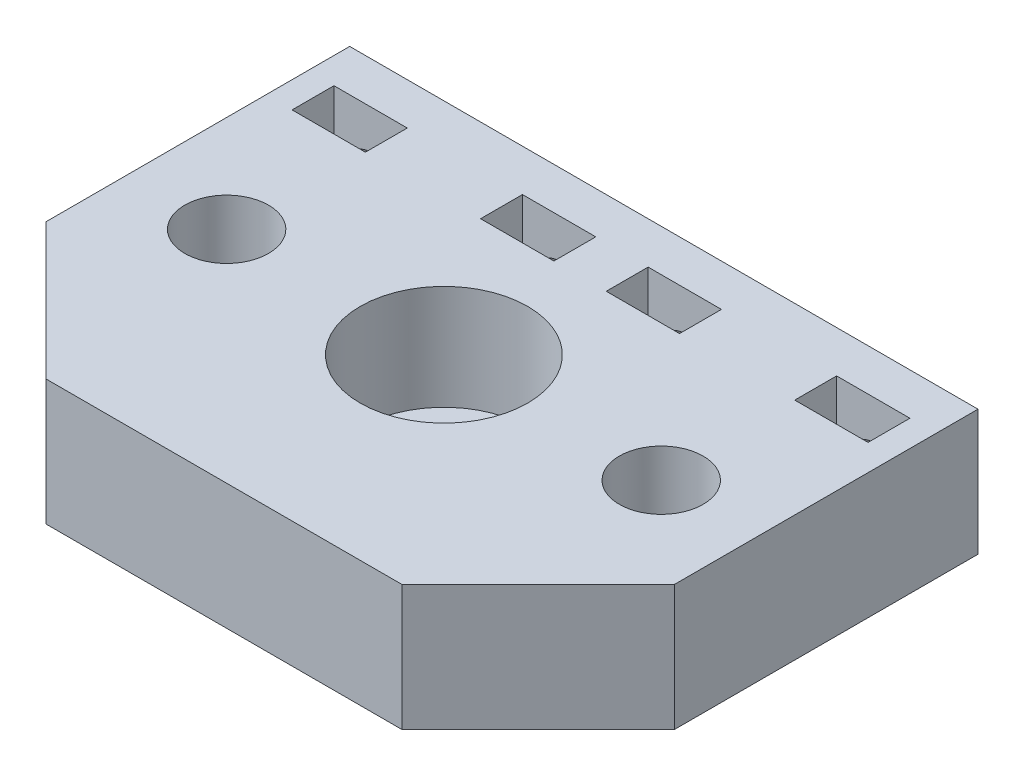
from build123d import *

# Parameters (mm, degrees)
SKETCH1_W                      = 60
SKETCH1_H                      = 42
BOSS_EXTRUDE1_DEPTH            = 12
CUT_EXTRUDE1_REACH             = 14
SKETCH2_R                      = 4
CUT_EXTRUDE1_DIRECTION_2_DEPTH = 1
SKETCH3_R                      = 8
SKETCH3_R_2                    = 4
CUT_EXTRUDE2_DEPTH             = 1
CUT_EXTRUDE2_DEPTH_BACK        = 10
CHAMFER1_SIZE                  = 13
CUT_EXTRUDE4_REACH             = 14
SKETCH5_W                      = 7
SKETCH5_H                      = 4
CUT_EXTRUDE4_DIRECTION_2_DEPTH = 1
SKETCH4_R                      = 2.25
CUT_EXTRUDE3_DEPTH             = 7.5


with BuildPart() as part:
    # Sketch1 → Boss-Extrude1 (new body)
    with BuildSketch(Plane(origin=(0, 0, 0), x_dir=(1, 0, 0), z_dir=(0, 1, 0))):
        Rectangle(SKETCH1_W, SKETCH1_H)
    extrude(amount=BOSS_EXTRUDE1_DEPTH)

    # Sketch2 → Cut-Extrude1 (cut, up to next)
    with BuildSketch(Plane(origin=(0, 12, 0), x_dir=(1, 0, 0), z_dir=(0, 1, 0)), mode=Mode.PRIVATE) as cut_extrude1_sk1:
        Circle(SKETCH2_R)
    cut_extrude1_tool1 = extrude(cut_extrude1_sk1.sketch, amount=-CUT_EXTRUDE1_REACH, mode=Mode.PRIVATE) & part.part
    add(cut_extrude1_tool1.solids().sort_by_distance((0, 12, 0))[0], mode=Mode.SUBTRACT)

    # Sketch2 → Cut-Extrude1 direction 2 (cut)
    with BuildSketch(Plane(origin=(0, 12, 0), x_dir=(1, 0, 0), z_dir=(0, 1, 0))):
        Circle(SKETCH2_R)
    extrude(amount=CUT_EXTRUDE1_DIRECTION_2_DEPTH, mode=Mode.SUBTRACT)

    # Sketch3 → Cut-Extrude2 (cut, two sides)
    with BuildSketch(Plane(origin=(0, 12, 0), x_dir=(1, 0, 0), z_dir=(0, 1, 0))) as cut_extrude2_sk:
        Circle(SKETCH3_R)
        with Locations((20.75, 0)):
            Circle(SKETCH3_R_2)
        with Locations((-20.75, 0)):
            Circle(SKETCH3_R_2)
    extrude(amount=CUT_EXTRUDE2_DEPTH, mode=Mode.SUBTRACT)
    extrude(cut_extrude2_sk.sketch, amount=-CUT_EXTRUDE2_DEPTH_BACK, mode=Mode.SUBTRACT)

    # Chamfer1
    chamfer1_edges = [part.edges().sort_by_distance(p)[0] for p in [
        (30, 6, 21),
        (-30, 6, 21),
    ]]
    chamfer(chamfer1_edges, length=CHAMFER1_SIZE)

    # Sketch5 → Cut-Extrude4 (cut, up to next)
    with BuildSketch(Plane(origin=(0, 12, 0), x_dir=(1, 0, 0), z_dir=(0, 1, 0)), mode=Mode.PRIVATE) as cut_extrude4_sk1:
        with Locations((24, 15)):
            Rectangle(SKETCH5_W, SKETCH5_H)
    cut_extrude4_tool1 = extrude(cut_extrude4_sk1.sketch, amount=-CUT_EXTRUDE4_REACH, mode=Mode.PRIVATE) & part.part
    add(cut_extrude4_tool1.solids().sort_by_distance((24, 12, -15))[0], mode=Mode.SUBTRACT)
    # Sketch5 → Cut-Extrude4 (cut, up to next)
    with BuildSketch(Plane(origin=(0, 12, 0), x_dir=(1, 0, 0), z_dir=(0, 1, 0)), mode=Mode.PRIVATE) as cut_extrude4_sk2:
        with Locations((6, 15)):
            Rectangle(SKETCH5_W, SKETCH5_H)
    cut_extrude4_tool2 = extrude(cut_extrude4_sk2.sketch, amount=-CUT_EXTRUDE4_REACH, mode=Mode.PRIVATE) & part.part
    add(cut_extrude4_tool2.solids().sort_by_distance((6, 12, -15))[0], mode=Mode.SUBTRACT)
    # Sketch5 → Cut-Extrude4 (cut, up to next)
    with BuildSketch(Plane(origin=(0, 12, 0), x_dir=(1, 0, 0), z_dir=(0, 1, 0)), mode=Mode.PRIVATE) as cut_extrude4_sk3:
        with Locations((-6, 15)):
            Rectangle(SKETCH5_W, SKETCH5_H)
    cut_extrude4_tool3 = extrude(cut_extrude4_sk3.sketch, amount=-CUT_EXTRUDE4_REACH, mode=Mode.PRIVATE) & part.part
    add(cut_extrude4_tool3.solids().sort_by_distance((-6, 12, -15))[0], mode=Mode.SUBTRACT)
    # Sketch5 → Cut-Extrude4 (cut, up to next)
    with BuildSketch(Plane(origin=(0, 12, 0), x_dir=(1, 0, 0), z_dir=(0, 1, 0)), mode=Mode.PRIVATE) as cut_extrude4_sk4:
        with Locations((-24, 15)):
            Rectangle(SKETCH5_W, SKETCH5_H)
    cut_extrude4_tool4 = extrude(cut_extrude4_sk4.sketch, amount=-CUT_EXTRUDE4_REACH, mode=Mode.PRIVATE) & part.part
    add(cut_extrude4_tool4.solids().sort_by_distance((-24, 12, -15))[0], mode=Mode.SUBTRACT)

    # Sketch5 → Cut-Extrude4 direction 2 (cut)
    with BuildSketch(Plane(origin=(0, 12, 0), x_dir=(1, 0, 0), z_dir=(0, 1, 0))):
        with Locations((24, 15)):
            Rectangle(SKETCH5_W, SKETCH5_H)
        with Locations((6, 15)):
            Rectangle(SKETCH5_W, SKETCH5_H)
        with Locations((-6, 15)):
            Rectangle(SKETCH5_W, SKETCH5_H)
        with Locations((-24, 15)):
            Rectangle(SKETCH5_W, SKETCH5_H)
    extrude(amount=CUT_EXTRUDE4_DIRECTION_2_DEPTH, mode=Mode.SUBTRACT)

    # Sketch4 → Cut-Extrude3 (cut)
    with BuildSketch(Plane(origin=(0, 0, -21), x_dir=(-1, 0, 0), z_dir=(0, 0, -1))):
        with Locations((-24, 6)):
            Circle(SKETCH4_R)
        with Locations((-6, 6)):
            Circle(SKETCH4_R)
        with Locations((6, 6)):
            Circle(SKETCH4_R)
        with Locations((24, 6)):
            Circle(SKETCH4_R)
    extrude(amount=-CUT_EXTRUDE3_DEPTH, mode=Mode.SUBTRACT)


solid = part.part
